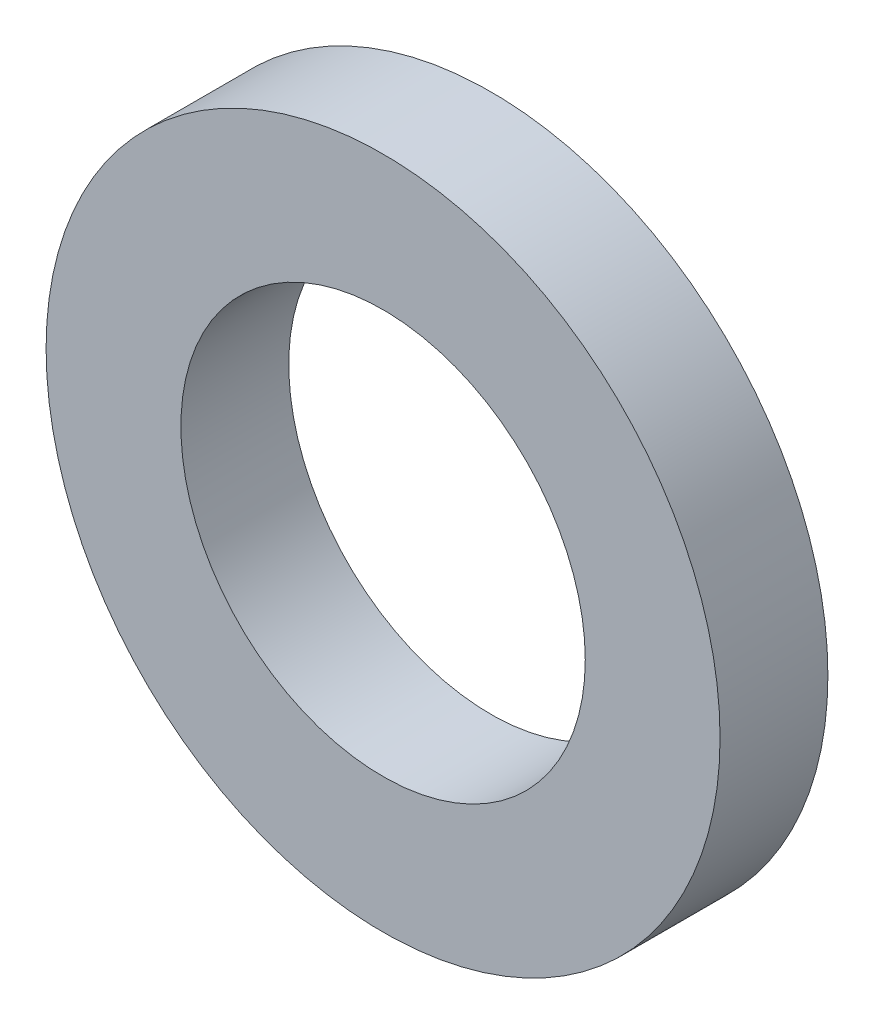
from build123d import *

# Parameters (mm, degrees)
SKETCH1_R           = 3.75
SKETCH1_R_2         = 2.25
BOSS_EXTRUDE1_DEPTH = 1.2


with BuildPart() as part:
    # Sketch1 → Boss-Extrude1 (new body)
    with BuildSketch(Plane.XY):
        Circle(SKETCH1_R)
        Circle(SKETCH1_R_2, mode=Mode.SUBTRACT)
    extrude(amount=BOSS_EXTRUDE1_DEPTH)


solid = part.part
